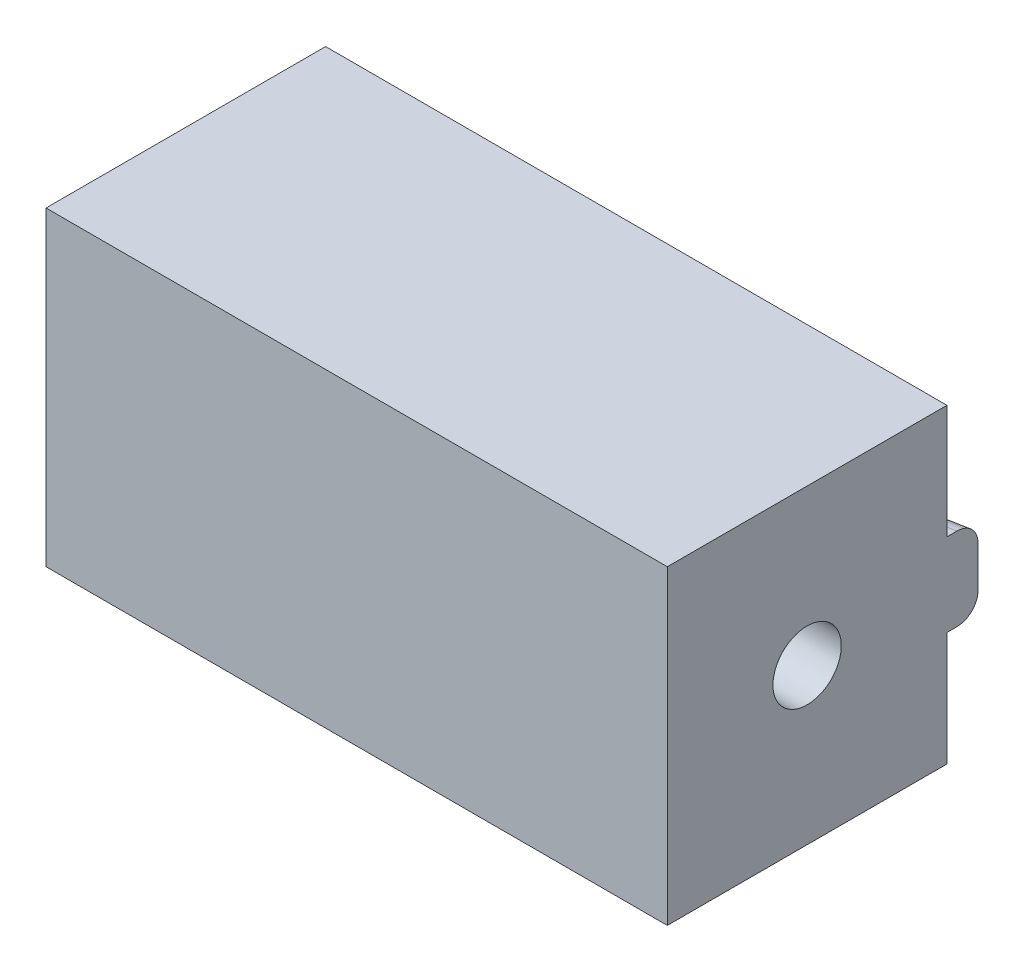
from build123d import *

# Parameters (mm, degrees)
SKETCH1_W           = 30
SKETCH1_H           = 15
BOSS_EXTRUDE1_DEPTH = 6.75
SKETCH3_R           = 1.5
CUT_EXTRUDE1_DEPTH  = 3
BOSS_EXTRUDE2_DEPTH = 2
FILLET1_R           = 1


with BuildPart() as part:
    # Sketch1 → Boss-Extrude1 (new, symmetric)
    with BuildSketch(Plane.XY):
        with Locations((15, 0)):
            Rectangle(SKETCH1_W, SKETCH1_H)
    extrude(amount=BOSS_EXTRUDE1_DEPTH, both=True)

    # Sketch3 → Cut-Extrude1 (cut)
    with BuildSketch(Plane.XZ.offset(7.5)):
        with Locations((8, 0)):
            Circle(SKETCH3_R)
        with Locations((23, 0)):
            Circle(SKETCH3_R)
    extrude(amount=-CUT_EXTRUDE1_DEPTH, mode=Mode.SUBTRACT)

    # Sketch4 → Boss-Extrude2 (add, symmetric)
    with BuildSketch(Plane(origin=(0, 0, 0), x_dir=(1, 0, 0), z_dir=(0, 1, 0))):
        Polygon((30, 6.75), (30, 8.25), (22, 6.75), align=None)
    extrude(amount=BOSS_EXTRUDE2_DEPTH, both=True)

    # Fillet1
    fillet1_edges = [part.edges().sort_by_distance(p)[0] for p in [
        (26, 2, -7.5),
        (26, -2, -7.5),
    ]]
    fillet(fillet1_edges, radius=FILLET1_R)

    # Sketch2 → Cut-Revolve1 (revolve, cut)
    with BuildSketch(Plane(origin=(0, 0, 0), x_dir=(1, 0, 0), z_dir=(0, 1, 0))):
        Polygon((0, 0), (30, 0), (30, 1.65), (22.5, 1.65), (22.5, 3), (0, 3), align=None)
    revolve(axis=Axis((0, 0, 0), (1, 0, 0)), mode=Mode.SUBTRACT)


solid = part.part
